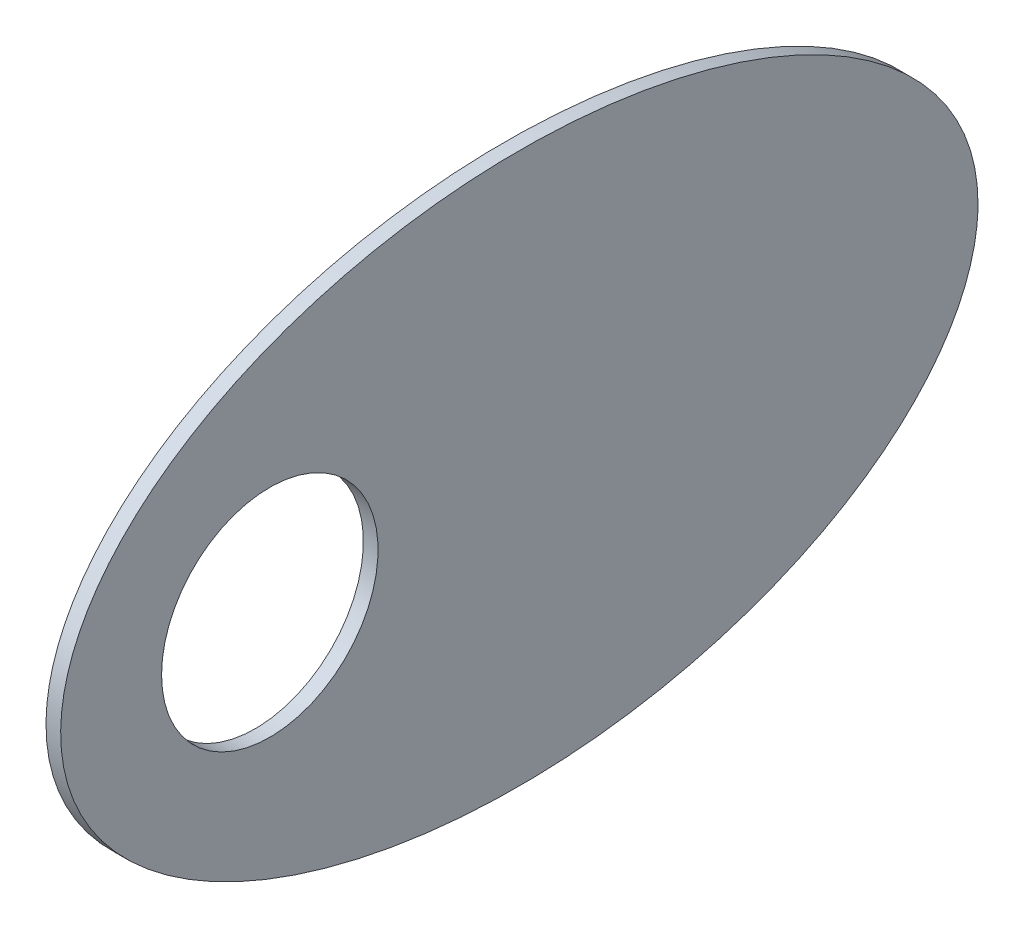
from build123d import *

# Parameters (mm, degrees)
SKETCH1_RX          = 125
SKETCH1_RY          = 75
BOSS_EXTRUDE1_DEPTH = 4
SKETCH2_R           = 29.5
CUT_EXTRUDE1_DEPTH  = 5


with BuildPart() as part:
    # Sketch1 → Boss-Extrude1 (new body)
    with BuildSketch(Plane(origin=(0, 0, 0), x_dir=(0, 0, -1), z_dir=(1, 0, 0))):
        with Locations((0, 0)):
            Ellipse(SKETCH1_RX, SKETCH1_RY)
    extrude(amount=BOSS_EXTRUDE1_DEPTH)

    # Sketch2 → Cut-Extrude1 (cut, through all)
    with BuildSketch(Plane.ZY):
        with Locations((68, 0)):
            Circle(SKETCH2_R)
    extrude(amount=-CUT_EXTRUDE1_DEPTH, mode=Mode.SUBTRACT)


solid = part.part
